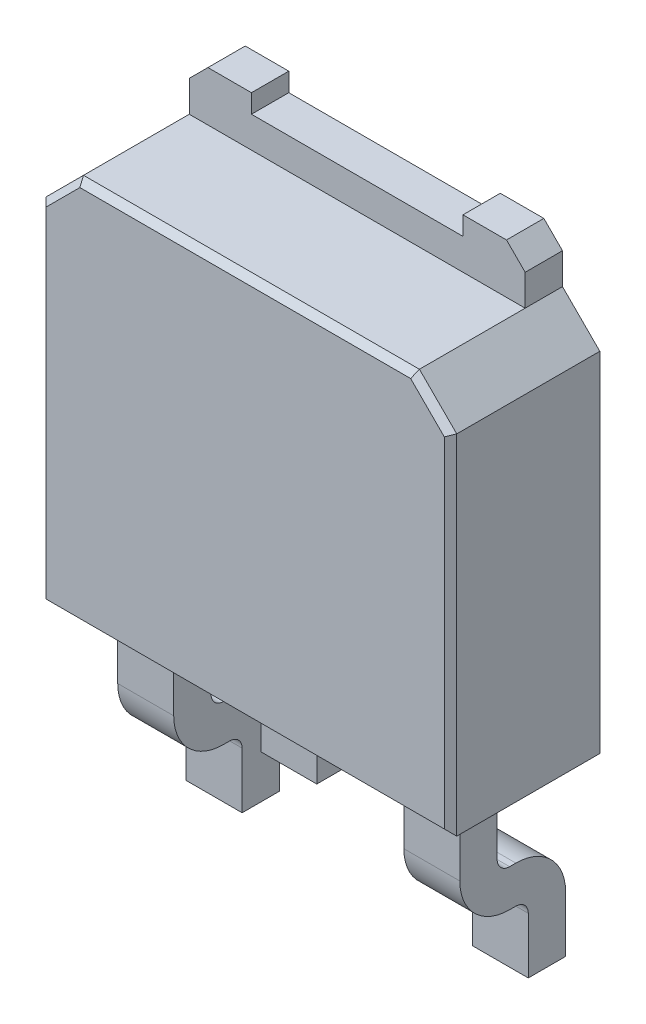
from build123d import *

# Parameters (mm, degrees)
SKIZZE1_W                       = 6.6
SKIZZE1_H                       = 6.2
LINEAR_AUSTRAGEN1_DEPTH         = 2.4
FASE2_SIZE                      = 0.6
SKIZZE2_W                       = 0.9
SKIZZE2_H                       = 0.6
SKIZZE3_W                       = 0.9
SKIZZE3_H                       = 0.6
LINEAR_AUSTRAGEN2_DEPTH         = 1
SKIZZE4_W                       = 5.4
SKIZZE4_H                       = 0.6
LINEAR_AUSTRAGEN3_DEPTH         = 0.8
SKIZZE5_W                       = 3.4
SKIZZE5_H                       = 0.6
SCHNITT_LINEAR_AUSTRAGEN1_DEPTH = 0.3
FASE3_SIZE                      = 0.3
FASE4_SIZE                      = 0.1


with BuildPart() as part:
    # Skizze1 → Linear austragen1 (new body)
    with BuildSketch(Plane.XY):
        Rectangle(SKIZZE1_W, SKIZZE1_H)
    extrude(amount=LINEAR_AUSTRAGEN1_DEPTH)

    # Fase2
    fase2_edges = [part.edges().sort_by_distance(p)[0] for p in [
        (-3.3, 3.1, 1.2),
        (3.3, 3.1, 1.2),
    ]]
    chamfer(fase2_edges, length=FASE2_SIZE)

    # Austragung1: sweep along a curve in space
    with BuildLine() as austragung1_path:
        Line((2.3, -3.1, 1.4), (2.3, -4.3, 1.4))
        ThreePointArc((2.3, -4.3, 1.4), (2.3, -4.653553391, 1.253553391), (2.3, -4.8, 0.9))
        Line((2.3, -4.8, 0.9), (2.3, -4.8, 0.8))
        ThreePointArc((2.3, -4.8, 0.8), (2.3, -4.946446609, 0.446446609), (2.3, -5.3, 0.3))
        Line((2.3, -5.3, 0.3), (2.3, -6.2, 0.3))
    # Skizze2 → Austragung1 (sweep)
    with BuildSketch(Plane.XZ.offset(3.1)):
        with Locations((2.3, 1.4)):
            Rectangle(SKIZZE2_W, SKIZZE2_H)
    austragung1 = sweep(path=austragung1_path.line)

    # Spiegeln1: Austragung1 across plane
    add(austragung1.mirror(Plane(origin=(0, 0, 0), x_dir=(0, 0, 1), z_dir=(1, 0, 0))))

    # Skizze3 → Linear austragen2 (add)
    with BuildSketch(Plane.XZ.offset(3.1)):
        with Locations((0, 1.4)):
            Rectangle(SKIZZE3_W, SKIZZE3_H)
    extrude(amount=LINEAR_AUSTRAGEN2_DEPTH)

    # Skizze4 → Linear austragen3 (add)
    with BuildSketch(Plane(origin=(0, 3.1, 0), x_dir=(-1, 0, 0), z_dir=(0, 1, 0))):
        with Locations((0, 0.3)):
            Rectangle(SKIZZE4_W, SKIZZE4_H)
    extrude(amount=LINEAR_AUSTRAGEN3_DEPTH)

    # Skizze5 → Schnitt-Linear austragen1 (cut)
    with BuildSketch(Plane(origin=(0, 3.9, 0), x_dir=(-1, 0, 0), z_dir=(0, 1, 0))):
        with Locations((0, 0.3)):
            Rectangle(SKIZZE5_W, SKIZZE5_H)
    extrude(amount=-SCHNITT_LINEAR_AUSTRAGEN1_DEPTH, mode=Mode.SUBTRACT)

    # Fase3
    fase3_edges = [part.edges().sort_by_distance(p)[0] for p in [
        (-2.7, 3.9, 0.3),
        (2.7, 3.9, 0.3),
    ]]
    chamfer(fase3_edges, length=FASE3_SIZE)

    # Fase4
    fase4_edges = [part.edges().sort_by_distance(p)[0] for p in [
        (0, -3.1, 2.4),
        (-3.3, -0.3, 2.4),
        (-3, 2.8, 2.4),
        (0, 3.1, 2.4),
        (3, 2.8, 2.4),
        (3.3, -0.3, 2.4),
    ]]
    chamfer(fase4_edges, length=FASE4_SIZE)


solid = part.part
